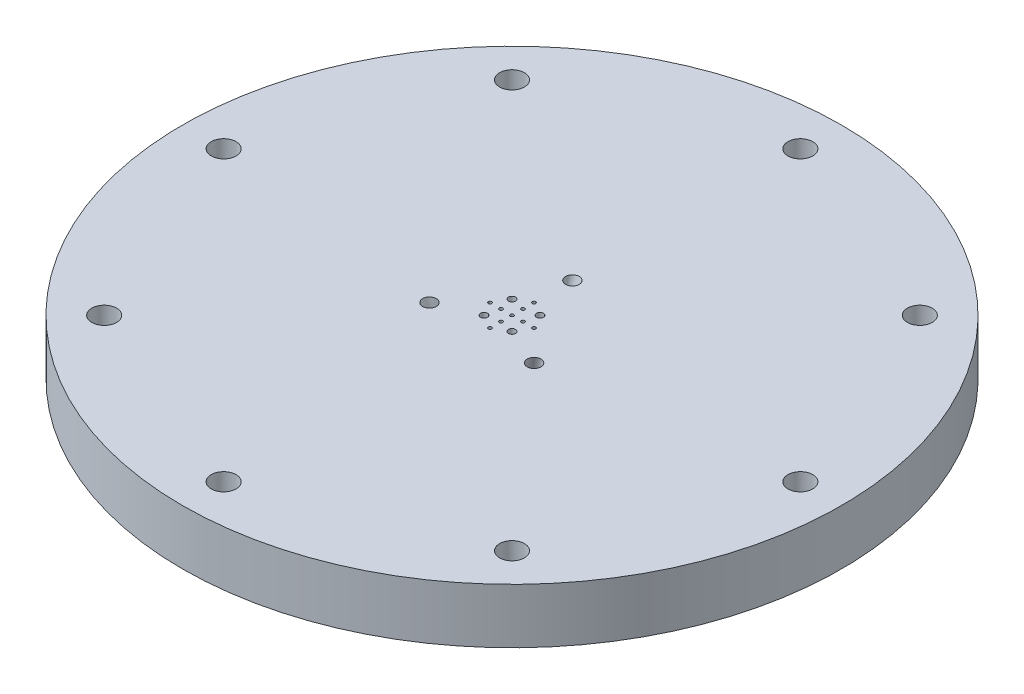
from build123d import *

# Parameters (mm, degrees)
SKETCH1_R                                      = 38.1
BOSS_EXTRUDE1_DEPTH                            = 6.35
CBORE_FOR_4_BUTTON_HEAD_CAP_SCREW1_D           = 2.8702
CBORE_FOR_4_BUTTON_HEAD_CAP_SCREW1_CBORE_D     = 4.826
CBORE_FOR_4_BUTTON_HEAD_CAP_SCREW1_CBORE_DEPTH = 2.794
CIRPATTERN1_COUNT                              = 8
SKETCH6_R                                      = 0.1984375
CUT_EXTRUDE1_DEPTH                             = 55.254423783
CIRPATTERN2_COUNT                              = 4
SKETCH6_3_R                                    = 0.1984375
CUT_EXTRUDE2_DEPTH                             = 55.254423783
SKETCH6_5_R                                    = 0.408305
CUT_EXTRUDE4_DEPTH                             = 55.254423783
CIRPATTERN4_COUNT                              = 4
SKETCH7_R                                      = 0.79375
CIRPATTERN6_COUNT                              = 3


with BuildPart() as part:
    # Sketch1 → Boss-Extrude1 (new body)
    with BuildSketch(Plane(origin=(0, 0, 0), x_dir=(1, 0, 0), z_dir=(0, 1, 0))):
        Circle(SKETCH1_R)
    extrude(amount=BOSS_EXTRUDE1_DEPTH)

    # CBORE for _4 Button Head Cap Screw1 (through all)
    with Locations(Plane(origin=(0, 0, 0), x_dir=(-1, 0, 0), z_dir=(0, -1, 0))):
        with Locations((0, -33.3375)):
            cbore_for_4_button_head_cap_screw1 = CounterBoreHole(CBORE_FOR_4_BUTTON_HEAD_CAP_SCREW1_D / 2, CBORE_FOR_4_BUTTON_HEAD_CAP_SCREW1_CBORE_D / 2, CBORE_FOR_4_BUTTON_HEAD_CAP_SCREW1_CBORE_DEPTH)

    # CirPattern1: CBORE for _4 Button Head Cap Screw1 ×8 about axis
    cirpattern1_axis = Axis((0, 0, 0), (0, 1, 0))
    for i in range(1, CIRPATTERN1_COUNT):
        add(cbore_for_4_button_head_cap_screw1.rotate(cirpattern1_axis, i * 360 / CIRPATTERN1_COUNT), mode=Mode.SUBTRACT)

    # Sketch6 → Cut-Extrude1 (cut, through all)
    with BuildSketch(Plane.XZ):
        with Locations((0, -2.54)):
            Circle(SKETCH6_R)
        with Locations((0, -1.27)):
            Circle(SKETCH6_R)
    cut_extrude1 = extrude(amount=-CUT_EXTRUDE1_DEPTH, mode=Mode.SUBTRACT)

    # CirPattern2: Cut-Extrude1 ×4 about axis
    cirpattern2_axis = Axis((0, 0, 0), (0, -1, 0))
    for i in range(1, CIRPATTERN2_COUNT):
        add(cut_extrude1.rotate(cirpattern2_axis, i * 360 / CIRPATTERN2_COUNT), mode=Mode.SUBTRACT)

    # Sketch6_3 → Cut-Extrude2 (cut, through all)
    with BuildSketch(Plane.XZ):
        Circle(SKETCH6_3_R)
    extrude(amount=-CUT_EXTRUDE2_DEPTH, mode=Mode.SUBTRACT)

    # Sketch6_5 → Cut-Extrude4 (cut, through all)
    with BuildSketch(Plane.XZ):
        with Locations((1.616446102, -1.616446102)):
            Circle(SKETCH6_5_R)
    cut_extrude4 = extrude(amount=-CUT_EXTRUDE4_DEPTH, mode=Mode.SUBTRACT)

    # CirPattern4: Cut-Extrude4 ×4 about axis
    cirpattern4_axis = Axis((0, 6.35, 0), (0, -1, 0))
    for i in range(1, CIRPATTERN4_COUNT):
        add(cut_extrude4.rotate(cirpattern4_axis, i * 360 / CIRPATTERN4_COUNT), mode=Mode.SUBTRACT)

    # Cut-Sweep1: sweep along a curve in space
    with BuildLine() as cut_sweep1_path:
        Line((0, 6.35, -6.985), (0, 0, -5.08))
    # Sketch7 → Cut-Sweep1 (sweep, cut)
    with BuildSketch(Plane(origin=(0, 6.35, 0), x_dir=(1, 0, 0), z_dir=(0, 1, 0))):
        with Locations((0, 6.985)):
            Circle(SKETCH7_R)
    cut_sweep1 = sweep(path=cut_sweep1_path.line, mode=Mode.SUBTRACT)

    # CirPattern6: Cut-Sweep1 ×3 about axis
    cirpattern6_axis = Axis((0, 6.35, 0), (0, -1, 0))
    for i in range(1, CIRPATTERN6_COUNT):
        add(cut_sweep1.rotate(cirpattern6_axis, i * 360 / CIRPATTERN6_COUNT), mode=Mode.SUBTRACT)


solid = part.part
